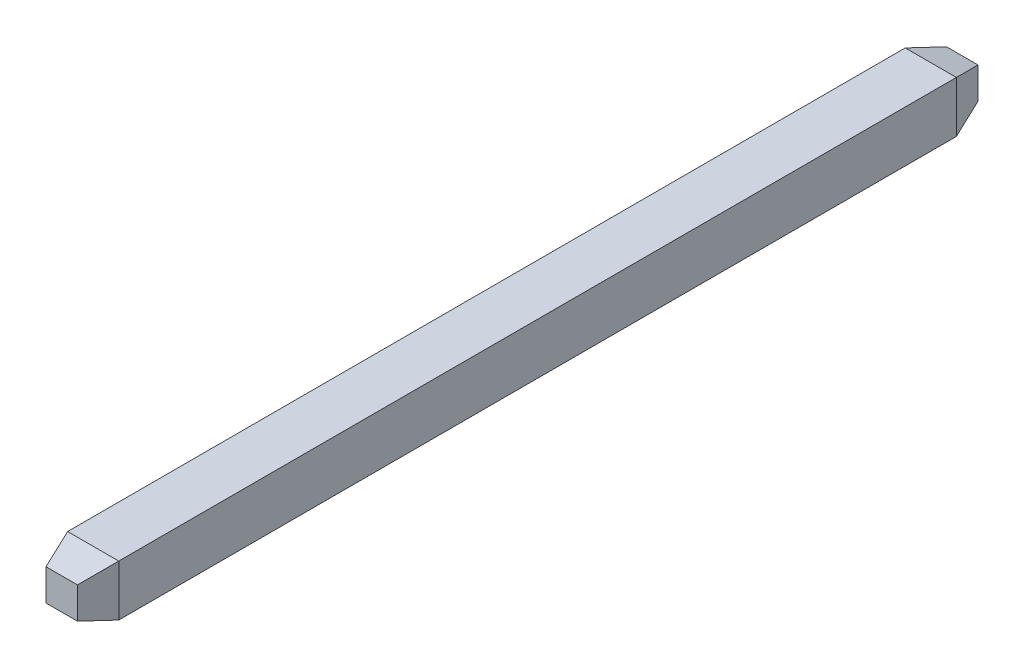
from build123d import *

# Parameters (mm, degrees)
ESQUISSE1_W             = 0.65
ESQUISSE1_H             = 0.65
BOSS_EXTRU_1_DEPTH      = 6
BOSS_EXTRU_1_DEPTH_BACK = 5.45
CHANFREIN1_SIZE         = 0.4
CHANFREIN1_SIZE2        = 0.125
CHANFREIN1_PART_2_SIZE  = 0.4
CHANFREIN1_PART_2_SIZE2 = 0.125
CHANFREIN1_PART_3_SIZE  = 0.4
CHANFREIN1_PART_3_SIZE2 = 0.125
CHANFREIN1_PART_4_SIZE  = 0.4
CHANFREIN1_PART_4_SIZE2 = 0.125
CHANFREIN2_SIZE         = 0.125
CHANFREIN2_SIZE2        = 0.4


with BuildPart() as part:
    # Esquisse1 → Boss.-Extru.1 (new body, two sides)
    with BuildSketch(Plane.XY) as boss_extru_1_sk:
        Rectangle(ESQUISSE1_W, ESQUISSE1_H)
    extrude(amount=BOSS_EXTRU_1_DEPTH)
    extrude(boss_extru_1_sk.sketch, amount=-BOSS_EXTRU_1_DEPTH_BACK)

    # Chanfrein1
    chanfrein1_edges = [part.edges().sort_by_distance(p)[0] for p in [
        (0.325, 0, 6),
    ]]
    chanfrein1_side = [part.faces().sort_by_distance(p)[0] for p in [
        (0.325, 0, 0.275),
    ]]
    chamfer(chanfrein1_edges, length=CHANFREIN1_SIZE, length2=CHANFREIN1_SIZE2, reference=chanfrein1_side[0])

    # Chanfrein1 part 2
    chanfrein1_part_2_edges = [part.edges().sort_by_distance(p)[0] for p in [
        (0, 0.325, 6),
    ]]
    chanfrein1_part_2_side = [part.faces().sort_by_distance(p)[0] for p in [
        (0, 0.325, 0.275),
    ]]
    chamfer(chanfrein1_part_2_edges, length=CHANFREIN1_PART_2_SIZE, length2=CHANFREIN1_PART_2_SIZE2, reference=chanfrein1_part_2_side[0])

    # Chanfrein1 part 3
    chanfrein1_part_3_edges = [part.edges().sort_by_distance(p)[0] for p in [
        (-0.325, 0, 6),
    ]]
    chanfrein1_part_3_side = [part.faces().sort_by_distance(p)[0] for p in [
        (-0.325, 0, 0.275),
    ]]
    chamfer(chanfrein1_part_3_edges, length=CHANFREIN1_PART_3_SIZE, length2=CHANFREIN1_PART_3_SIZE2, reference=chanfrein1_part_3_side[0])

    # Chanfrein1 part 4
    chanfrein1_part_4_edges = [part.edges().sort_by_distance(p)[0] for p in [
        (0, -0.325, 6),
    ]]
    chanfrein1_part_4_side = [part.faces().sort_by_distance(p)[0] for p in [
        (0, -0.325, 0.275),
    ]]
    chamfer(chanfrein1_part_4_edges, length=CHANFREIN1_PART_4_SIZE, length2=CHANFREIN1_PART_4_SIZE2, reference=chanfrein1_part_4_side[0])

    # Chanfrein2
    chanfrein2_edges = [part.edges().sort_by_distance(p)[0] for p in [
        (-0.325, 0, -5.45),
        (0, -0.325, -5.45),
        (0.325, 0, -5.45),
        (0, 0.325, -5.45),
    ]]
    chanfrein2_side = [part.faces().sort_by_distance(p)[0] for p in [
        (0, 0, -5.45),
    ]]
    chamfer(chanfrein2_edges, length=CHANFREIN2_SIZE, length2=CHANFREIN2_SIZE2, reference=chanfrein2_side[0])


solid = part.part
